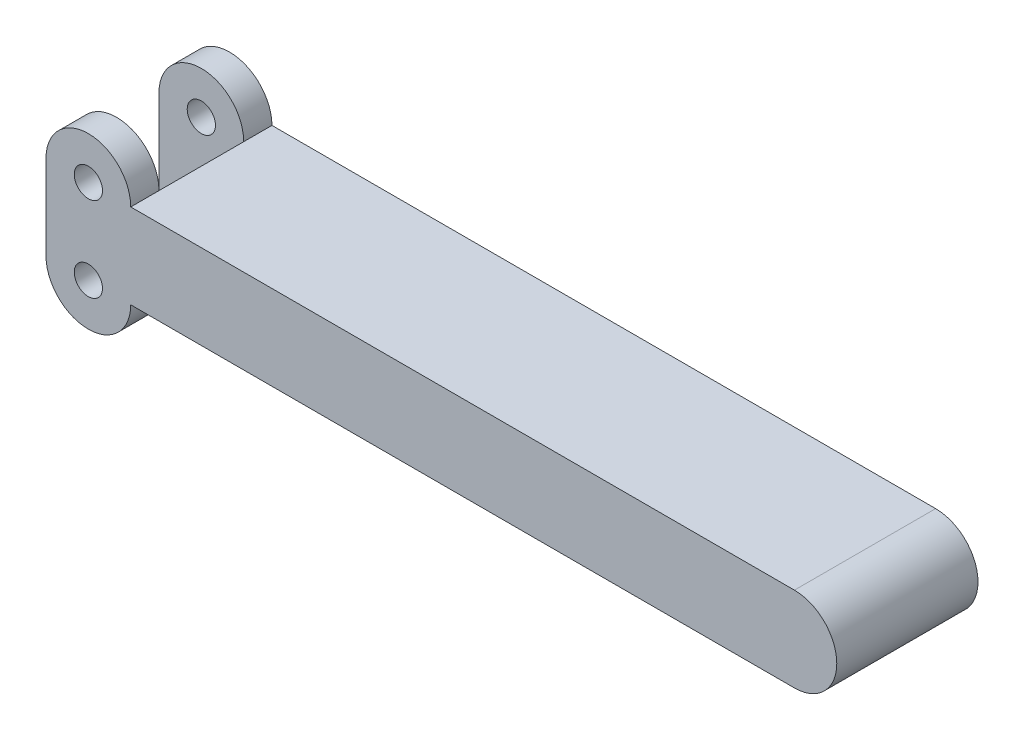
from build123d import *

# Parameters (mm, degrees)
SKETCH1_R           = 3.175
BOSS_EXTRUDE1_DEPTH = 31.75
SKETCH6_W           = 19.05
SKETCH6_H           = 19.05
SKETCH6_H_2         = 9.525
CUT_EXTRUDE1_DEPTH  = 19.05


with BuildPart() as part:
    # Sketch1 → Boss-Extrude1 (new body)
    with BuildSketch(Plane.XY):
        with BuildLine():
            Line((-9.525, 0), (-9.525, 19.05))
            ThreePointArc((-9.525, 19.05), (0, 28.575), (9.525, 19.05))
            Line((9.525, 19.05), (158.75, 19.05))
            ThreePointArc((158.75, 19.05), (168.275, 9.525), (158.75, 0))
            Line((158.75, 0), (9.525, 0))
            ThreePointArc((9.525, 0), (0, -9.525), (-9.525, 0))
        make_face()
        with Locations((0, 19.05)):
            Circle(SKETCH1_R, mode=Mode.SUBTRACT)
        Circle(SKETCH1_R, mode=Mode.SUBTRACT)
    extrude(amount=BOSS_EXTRUDE1_DEPTH)

    # Sketch6 → Cut-Extrude1 (cut)
    with BuildSketch(Plane.ZY.offset(9.525)):
        with Locations((15.875, 9.525)):
            Rectangle(SKETCH6_W, SKETCH6_H)
        with Locations((15.875, 23.8125)):
            Rectangle(SKETCH6_W, SKETCH6_H_2)
        with Locations((15.875, -4.7625)):
            Rectangle(SKETCH6_W, SKETCH6_H_2)
    extrude(amount=-CUT_EXTRUDE1_DEPTH, mode=Mode.SUBTRACT)


solid = part.part
